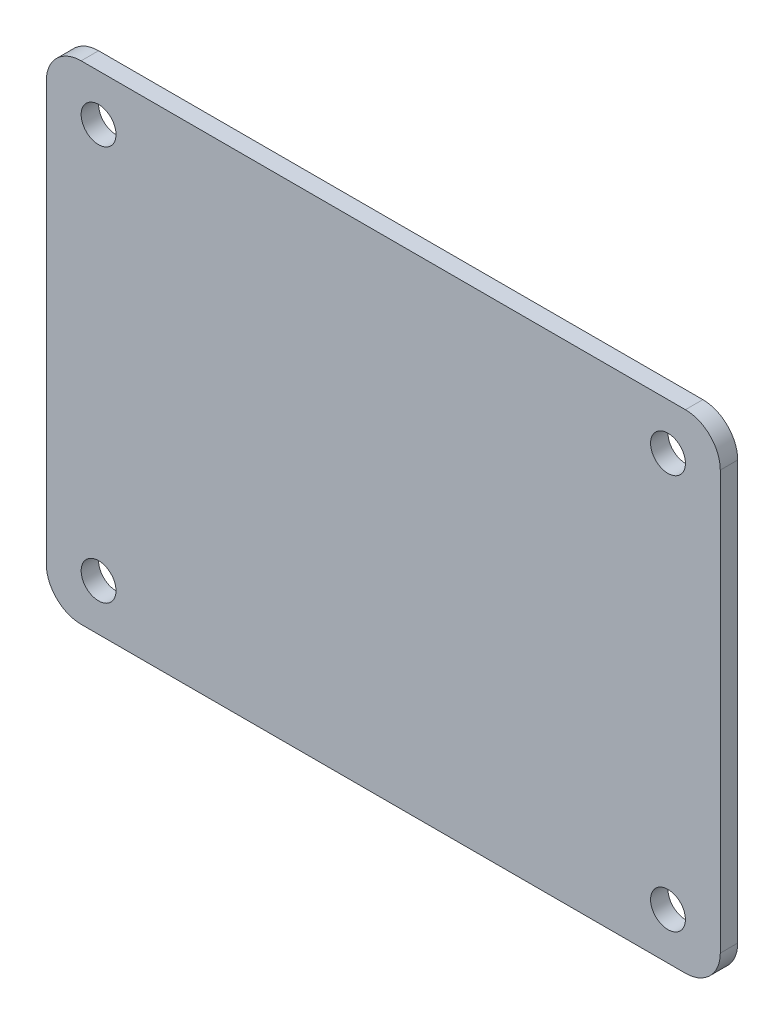
from build123d import *

# Parameters (mm, degrees)
SKETCH_1_W          = 58
SKETCH_1_H          = 42
EXTRUDE_1_DEPTH     = 1.5
SKETCH_2_R          = 1.5
CUT_EXTRUDE_1_DEPTH = 1.5
FILLET_1_R          = 3


with BuildPart() as part:
    # 草图1 → 凸台-拉伸1 (new body)
    with BuildSketch(Plane.XY):
        Rectangle(SKETCH_1_W, SKETCH_1_H)
    extrude(amount=EXTRUDE_1_DEPTH)

    # 草图2 → 切除-拉伸1 (cut)
    with BuildSketch(Plane.XY.offset(1.5)):
        with Locations((-24.5, 17)):
            Circle(SKETCH_2_R)
        with Locations((-24.5, -17)):
            Circle(SKETCH_2_R)
        with Locations((24.5, -17)):
            Circle(SKETCH_2_R)
        with Locations((24.5, 17)):
            Circle(SKETCH_2_R)
    extrude(amount=-CUT_EXTRUDE_1_DEPTH, mode=Mode.SUBTRACT)

    # 圆角1
    fillet_1_edges = [part.edges().sort_by_distance(p)[0] for p in [
        (29, -21, 0.75),
        (-29, -21, 0.75),
        (-29, 21, 0.75),
        (29, 21, 0.75),
    ]]
    fillet(fillet_1_edges, radius=FILLET_1_R)


solid = part.part
